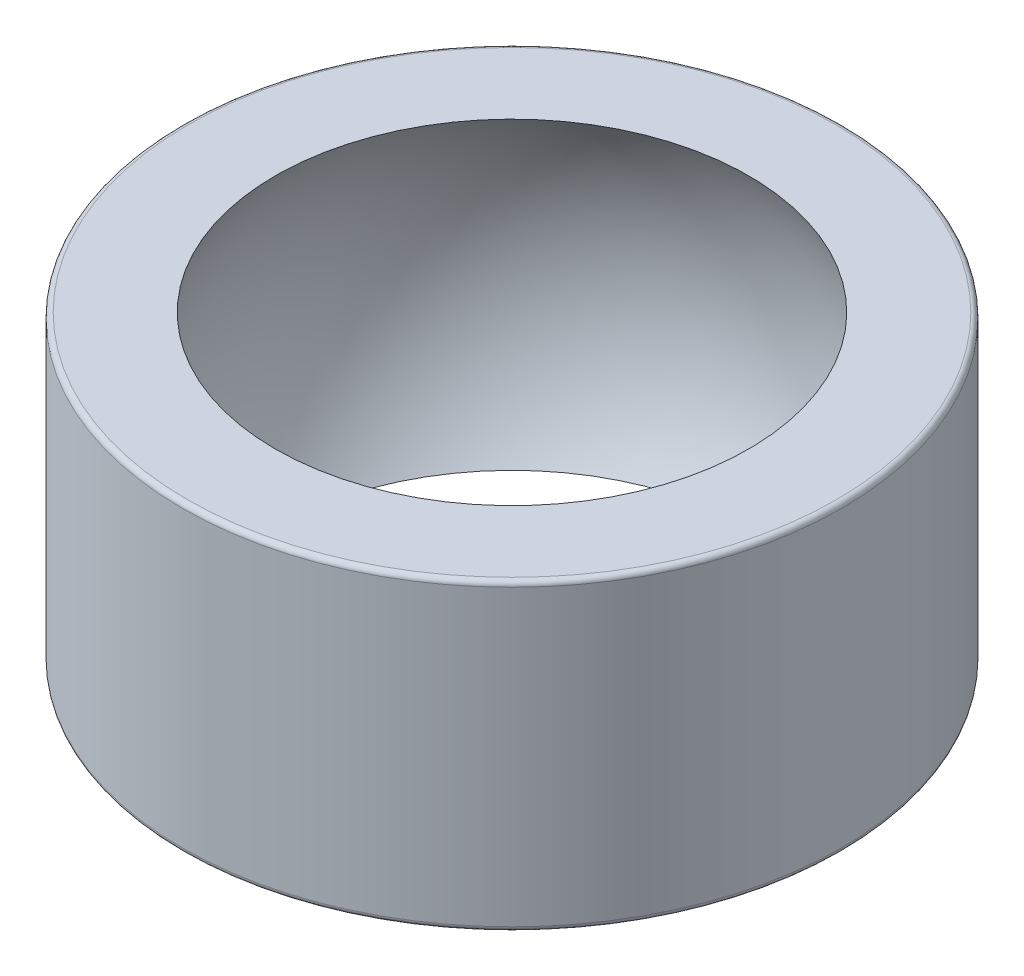
from build123d import *

# Parameters (mm, degrees)
SZKIC1_R                    = 13
DODANIE_WYCI_GNI_CIE1_DEPTH = 6
ZAOKR_GLENIE1_R             = 0.2


with BuildPart() as part:
    # Szkic1 → Dodanie-wyciągnięcie1 (new body, symmetric)
    with BuildSketch(Plane(origin=(0, 0, 0), x_dir=(1, 0, 0), z_dir=(0, 1, 0))):
        Circle(SZKIC1_R)
    extrude(amount=DODANIE_WYCI_GNI_CIE1_DEPTH, both=True)

    # Szkic3 → Wycięcie-obrót1 (revolve, cut)
    with BuildSketch(Plane.XY):
        with BuildLine():
            Line((0, -11.1), (0, 11.1))
            ThreePointArc((0, 11.1), (11.1, 0), (0, -11.1))
        make_face()
    revolve(axis=Axis((0, -11.1, 0), (0, 1, 0)), mode=Mode.SUBTRACT)

    # Zaokrąglenie1
    zaokr_glenie1_edges = [part.edges().sort_by_distance(p)[0] for p in [
        (-13, -6, 0),
        (-13, 6, 0),
    ]]
    fillet(zaokr_glenie1_edges, radius=ZAOKR_GLENIE1_R)


solid = part.part
